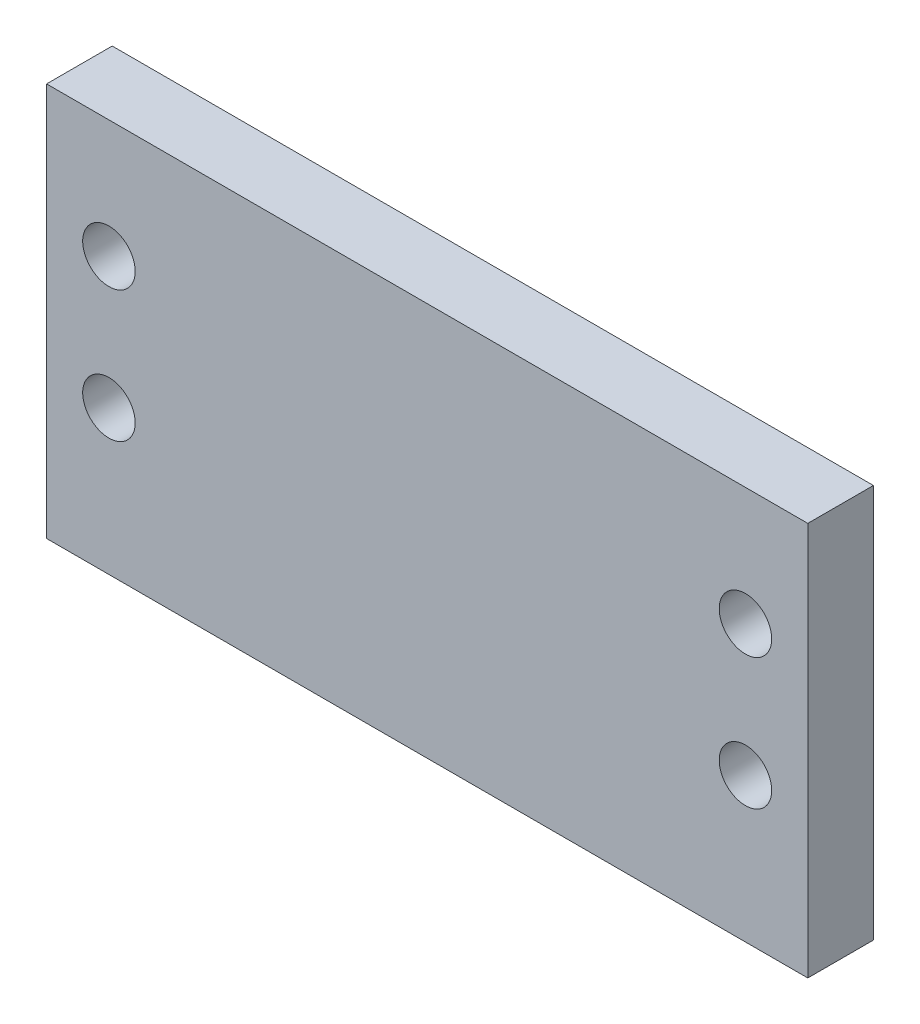
from build123d import *

# Parameters (mm, degrees)
SKETCH1_W           = 58
SKETCH1_H           = 30
SKETCH1_R           = 2
BOSS_EXTRUDE1_DEPTH = 5


with BuildPart() as part:
    # Sketch1 → Boss-Extrude1 (new body)
    with BuildSketch(Plane.XY):
        with Locations((-29, 15)):
            Rectangle(SKETCH1_W, SKETCH1_H)
        with Locations((-53.25, 21)):
            Circle(SKETCH1_R, mode=Mode.SUBTRACT)
        with Locations((-53.25, 11)):
            Circle(SKETCH1_R, mode=Mode.SUBTRACT)
        with Locations((-4.75, 21)):
            Circle(SKETCH1_R, mode=Mode.SUBTRACT)
        with Locations((-4.75, 11)):
            Circle(SKETCH1_R, mode=Mode.SUBTRACT)
    extrude(amount=BOSS_EXTRUDE1_DEPTH)


solid = part.part
